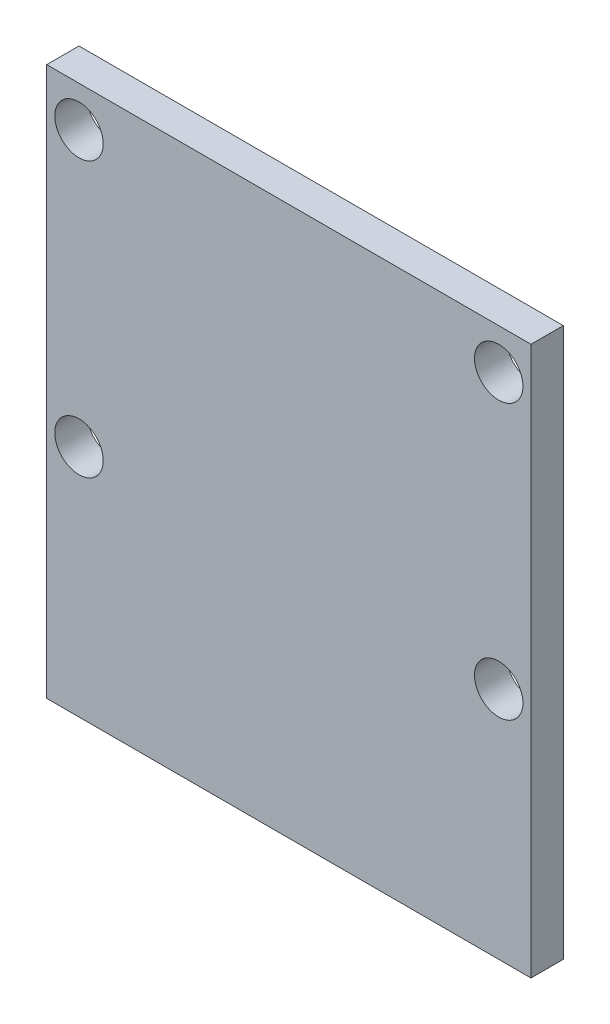
from build123d import *

# Parameters (mm, degrees)
SKETCH1_W           = 30
SKETCH1_H           = 34
SKETCH1_R           = 1.5
BOSS_EXTRUDE1_DEPTH = 2


with BuildPart() as part:
    # Sketch1 → Boss-Extrude1 (new body)
    with BuildSketch(Plane.XY):
        Rectangle(SKETCH1_W, SKETCH1_H)
        with Locations((-13, 14.5)):
            Circle(SKETCH1_R, mode=Mode.SUBTRACT)
        with Locations((13, 14.5)):
            Circle(SKETCH1_R, mode=Mode.SUBTRACT)
        with Locations((-13, -2.5)):
            Circle(SKETCH1_R, mode=Mode.SUBTRACT)
        with Locations((13, -2.5)):
            Circle(SKETCH1_R, mode=Mode.SUBTRACT)
    extrude(amount=BOSS_EXTRUDE1_DEPTH)


solid = part.part
